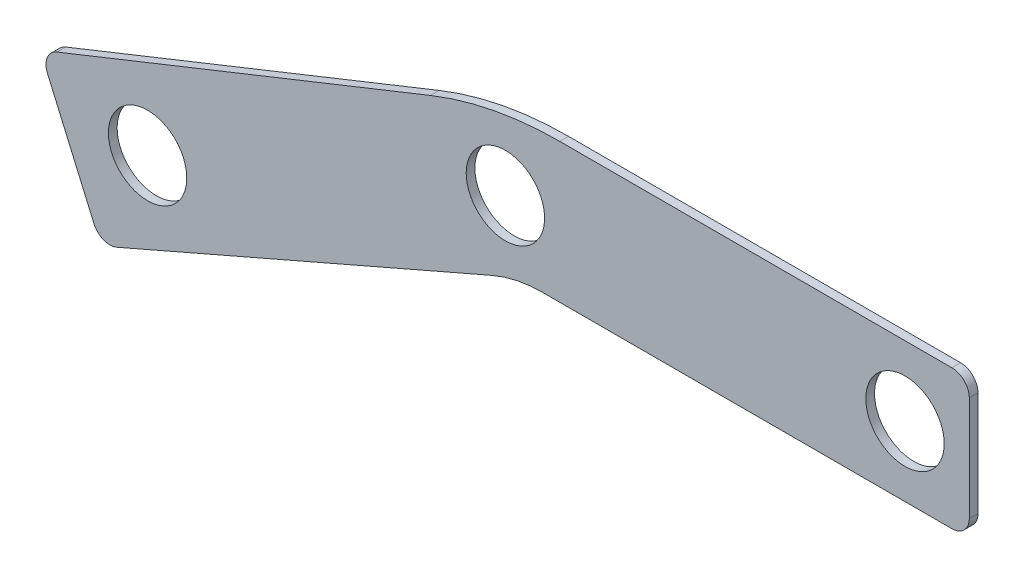
from build123d import *

# Parameters (mm, degrees)
BOSS_EXTRUDE1_DEPTH = 3.175
FILLET1_R           = 45.72
FILLET4_R           = 127
FILLET5_R           = 6.35
FILLET6_R           = 6.35
FILLET7_R           = 6.35
FILLET8_R           = 6.35
SKETCH4_R           = 14.2875
CUT_EXTRUDE1_DEPTH  = 18.415


with BuildPart() as part:
    # Sketch1 → Boss-Extrude1 (new body)
    with BuildSketch(Plane.XY):
        Polygon((0, 0), (165.1, 0), (165.1, 50.8), (-8.578307929, 50.8), (-173.494021533, -15.063128689), (-151.393719418, -65.863128689), align=None)
    extrude(amount=BOSS_EXTRUDE1_DEPTH)

    # Fillet1
    fillet1_edges = [part.edges().sort_by_distance(p)[0] for p in [
        (0, 0, 1.5875),
    ]]
    fillet(fillet1_edges, radius=FILLET1_R)

    # Fillet4
    fillet4_edges = [part.edges().sort_by_distance(p)[0] for p in [
        (-8.578307929, 50.8, 1.5875),
    ]]
    fillet(fillet4_edges, radius=FILLET4_R)

    # Fillet5
    fillet5_edges = [part.edges().sort_by_distance(p)[0] for p in [
        (-151.393719418, -65.863128689, 1.5875),
    ]]
    fillet(fillet5_edges, radius=FILLET5_R)

    # Fillet6
    fillet6_edges = [part.edges().sort_by_distance(p)[0] for p in [
        (-173.494021533, -15.063128689, 1.5875),
    ]]
    fillet(fillet6_edges, radius=FILLET6_R)

    # Fillet7
    fillet7_edges = [part.edges().sort_by_distance(p)[0] for p in [
        (165.1, 0, 1.5875),
    ]]
    fillet(fillet7_edges, radius=FILLET7_R)

    # Fillet8
    fillet8_edges = [part.edges().sort_by_distance(p)[0] for p in [
        (165.1, 50.8, 1.5875),
    ]]
    fillet(fillet8_edges, radius=FILLET8_R)

    # Sketch4 → Cut-Extrude1 (cut)
    with BuildSketch(Plane(origin=(0, 0, 0), x_dir=(-1, 0, 0), z_dir=(0, 0, -1))):
        with Locations((-141.674387764, 25.4)):
            Circle(SKETCH4_R)
        with Locations((134.369201797, -28.767007742)):
            Circle(SKETCH4_R)
        with Locations((3.969661405, 23.777990081)):
            Circle(SKETCH4_R)
    extrude(amount=-CUT_EXTRUDE1_DEPTH, mode=Mode.SUBTRACT)


solid = part.part
